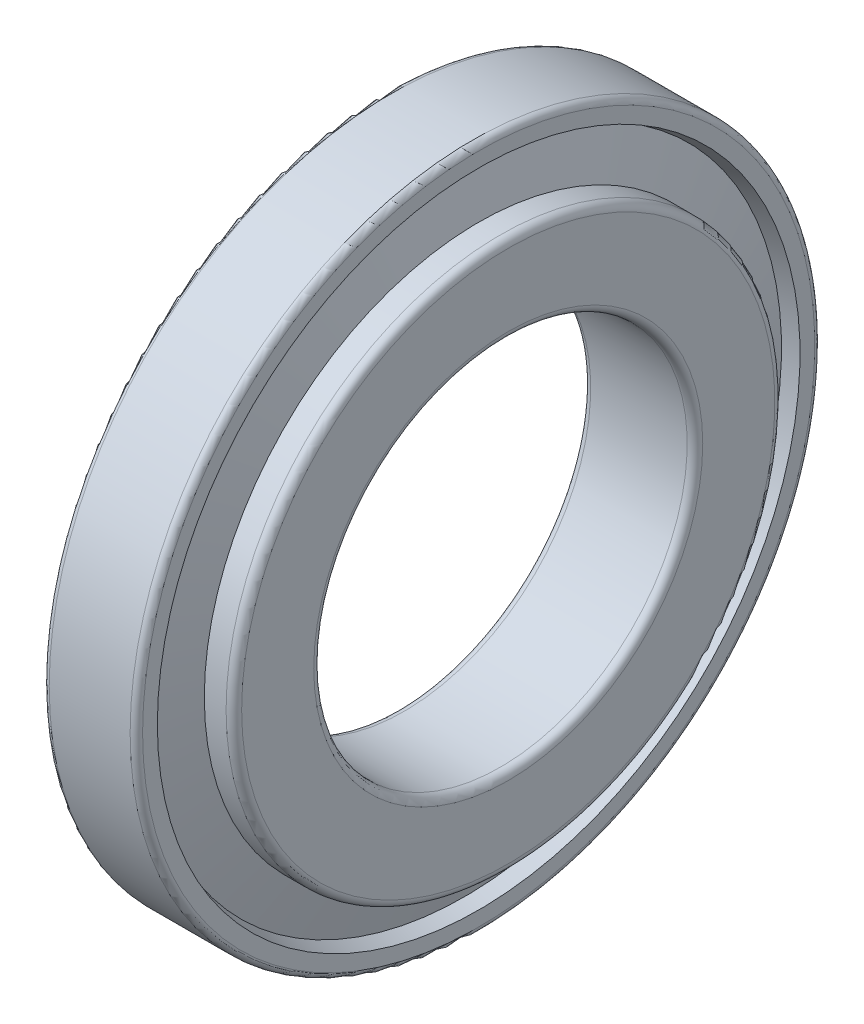
from build123d import *


with BuildPart() as part:
    # Эскиз1 → Повернуть1 (revolve)
    with BuildSketch(Plane.XY):
        with BuildLine():
            Line((15.361772444, 192.358196828), (0, 187.488))
            Line((0, 187.488), (0, 216))
            ThreePointArc((0, 216), (1.171572875, 218.828427125), (4, 220))
            Line((4, 220), (56, 220))
            ThreePointArc((56, 220), (58.828427125, 218.828427125), (60, 216))
            Line((60, 216), (60, 206.510011343))
            Line((60, 206.510011343), (50.953748731, 203.642046439))
            Line((50.953748731, 203.642046439), (60, 171.333953561))
            Line((60, 171.333953561), (60, 176.333953561))
            Line((60, 176.333953561), (74, 176.333953561))
            ThreePointArc((74, 176.333953561), (77.535533906, 174.869487467), (79, 171.333953561))
            Line((79, 171.333953561), (79, 125))
            ThreePointArc((79, 125), (77.535533906, 121.464466094), (74, 120))
            Line((74, 120), (12, 120))
            ThreePointArc((12, 120), (8.464466094, 121.464466094), (7, 125))
            Line((7, 125), (7, 162.494675163))
            Line((7, 162.494675163), (23.723544889, 162.494675163))
            Line((23.723544889, 162.494675163), (15.361772444, 192.358196828))
        make_face()
    revolve(axis=Axis((-882.527700014, 0, 0), (1, 0, 0)))


solid = part.part
